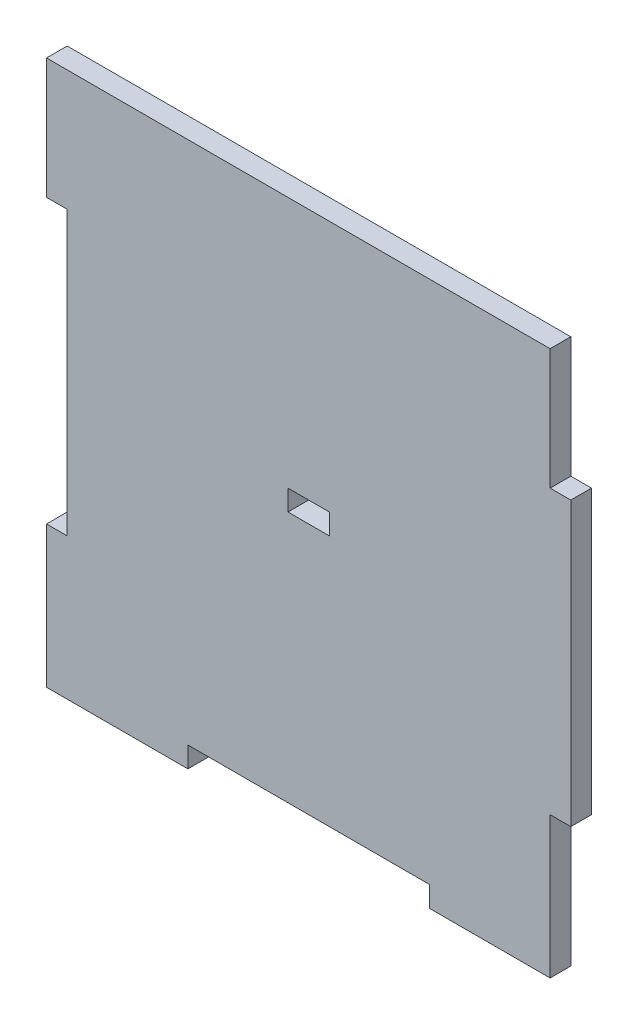
from build123d import *

# Parameters (mm, degrees)
BOSS_EXTRUDE1_DEPTH = 3
SKETCH2_W           = 6
SKETCH2_H           = 3
CUT_EXTRUDE1_DEPTH  = 3


with BuildPart() as part:
    # Sketch1 → Boss-Extrude1 (new body)
    with BuildSketch(Plane.XY):
        Polygon((-35, 38), (-17.5, 38), (17.5, 38), (35, 38), (35, 20.5), (38, 20.5), (38, -20.5), (35, -20.5), (35, -38), (35, -41), (17.5, -41), (17.5, -38), (-17.5, -38), (-17.5, -41), (-35, -41), (-38, -41), (-38, -38), (-38, -20.5), (-35, -20.5), (-35, 20.5), (-38, 20.5), (-38, 38), align=None)
    extrude(amount=BOSS_EXTRUDE1_DEPTH)

    # Sketch2 → Cut-Extrude1 (cut)
    with BuildSketch(Plane.XY.offset(3)):
        Rectangle(SKETCH2_W, SKETCH2_H)
    extrude(amount=-CUT_EXTRUDE1_DEPTH, mode=Mode.SUBTRACT)


solid = part.part
